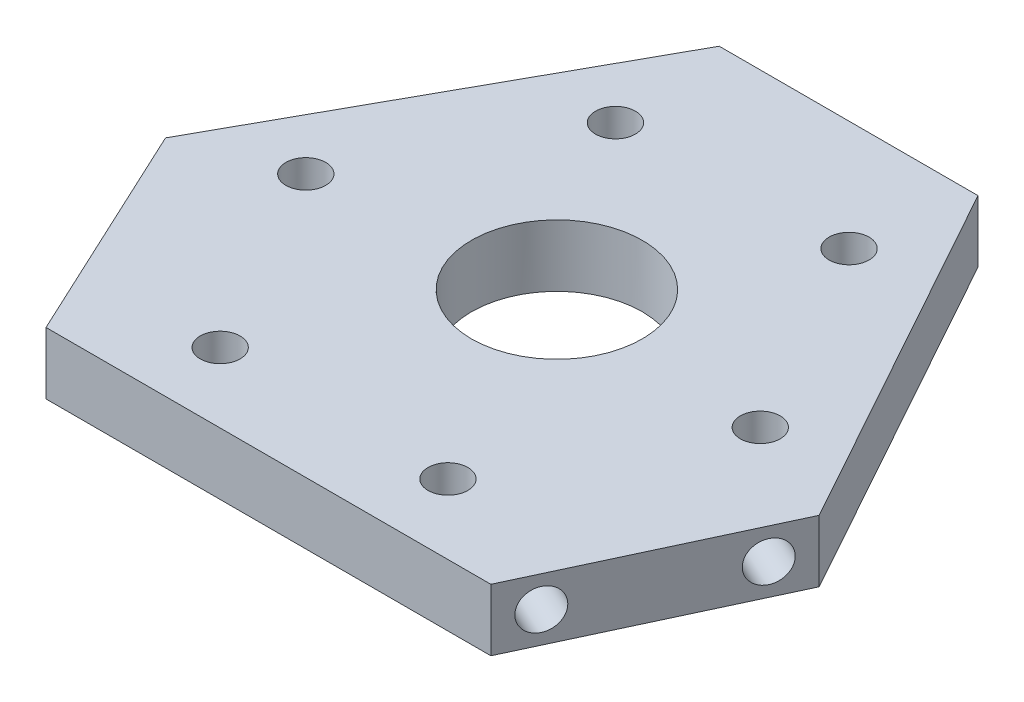
from build123d import *

# Parameters (mm, degrees)
BOSS_EXTRUDE1_DEPTH = 6.5
SCALE1_SCALE        = 0.85
SKETCH2_R           = 9
CUT_EXTRUDE1_DEPTH  = 10
SKETCH7_R           = 2.1
CUT_EXTRUDE7_DEPTH  = 6
SKETCH8_R           = 2.1
CUT_EXTRUDE8_DEPTH  = 6
SKETCH9_R           = 2.1
CUT_EXTRUDE9_DEPTH  = 6
SKETCH10_R          = 2.1
CUT_EXTRUDE10_DEPTH = 10
SKETCH12_R          = 2.1
SKETCH12_R_2        = 9
BOSS_EXTRUDE2_DEPTH = 0.5
SKETCH13_R          = 2.1
SKETCH13_R_2        = 9
BOSS_EXTRUDE3_DEPTH = 0.5


with BuildPart() as part:
    # Sketch1 → Boss-Extrude1 (new body)
    with BuildSketch(Plane(origin=(0, 0, 0), x_dir=(1, 0, 0), z_dir=(0, 1, 0))):
        Polygon((1.965722873, 0), (57.111381005, 0), (70.055583492, 27.758931813), (45.577412376, 71.918721468), (13.499691502, 71.918721468), (-10.978479614, 27.758931813), align=None)
    extrude(amount=BOSS_EXTRUDE1_DEPTH)


with BuildPart() as part_1:
    # Scale1: scaled about (29.538551939, 3.25, -32.913795141)
    add(part.part.scale(SCALE1_SCALE).moved(Location((4.430782791, 0.4875, -4.937069271))))

    # Sketch2 → Cut-Extrude1 (cut)
    with BuildSketch(Plane(origin=(0, 6.0125, 0), x_dir=(1, 0, 0), z_dir=(0, 1, 0))):
        with Locations((29.561028759, 35.307348014)):
            Circle(SKETCH2_R)
    extrude(amount=-CUT_EXTRUDE1_DEPTH, mode=Mode.SUBTRACT)

    # Sketch7 → Cut-Extrude7 (cut)
    with BuildSketch(Plane(origin=(6.902862477, 0, -3.218857636), x_dir=(0.422618262, 0, 0.906307787), z_dir=(-0.906307787, 0, 0.422618262))):
        with Locations((-23.930140333, 3.2525)):
            Circle(SKETCH7_R)
        with Locations((-5.895836778, 3.2525)):
            Circle(SKETCH7_R)
    extrude(amount=-CUT_EXTRUDE7_DEPTH, mode=Mode.SUBTRACT)

    # Sketch8 → Cut-Extrude8 (cut)
    with BuildSketch(Plane(origin=(0, 0, -66.067982519), x_dir=(-1, 0, 0), z_dir=(0, 0, -1))):
        with Locations((-39.17158331, 3.2525)):
            Circle(SKETCH8_R)
        with Locations((-19.905520568, 3.2525)):
            Circle(SKETCH8_R)
    extrude(amount=-CUT_EXTRUDE8_DEPTH, mode=Mode.SUBTRACT)

    # Sketch9 → Cut-Extrude9 (cut)
    with BuildSketch(Plane(origin=(41.622704657, 0, 19.408985935), x_dir=(0.422618262, 0, -0.906307787), z_dir=(0.906307787, 0, 0.422618262))):
        with Locations((30.862899728, 3.2525)):
            Circle(SKETCH9_R)
        with Locations((48.897203282, 3.2525)):
            Circle(SKETCH9_R)
    extrude(amount=-CUT_EXTRUDE9_DEPTH, mode=Mode.SUBTRACT)

    # Sketch10 → Cut-Extrude10 (cut)
    with BuildSketch(Plane.XZ.offset(-0.4875)):
        with Locations((41.211489709, -54.443494734)):
            Circle(SKETCH10_R)
        with Locations((52.846920595, -33.452621763)):
            Circle(SKETCH10_R)
        with Locations((17.41315777, -53.627241783)):
            Circle(SKETCH10_R)
        with Locations((5.777726884, -32.636368812)):
            Circle(SKETCH10_R)
        with Locations((17.101647233, -12.287069271)):
            Circle(SKETCH10_R)
        with Locations((41.101647233, -12.287069271)):
            Circle(SKETCH10_R)
    extrude(amount=-CUT_EXTRUDE10_DEPTH, mode=Mode.SUBTRACT)

    # Sketch12 → Boss-Extrude2 (add)
    with BuildSketch(Plane(origin=(0, 6.0125, 0), x_dir=(1, 0, 0), z_dir=(0, 1, 0))):
        Polygon((-4.900924881, 28.532161313), (6.101647233, 4.937069271), (52.975456645, 4.937069271), (63.978028759, 28.532161313), (43.17158331, 66.067982519), (15.905520568, 66.067982519), align=None)
        with Locations((17.101647233, 12.287069271)):
            Circle(SKETCH12_R, mode=Mode.SUBTRACT)
        with Locations((41.211489709, 54.443494734)):
            Circle(SKETCH12_R, mode=Mode.SUBTRACT)
        with Locations((29.561028759, 35.307348014)):
            Circle(SKETCH12_R_2, mode=Mode.SUBTRACT)
        with Locations((5.777726884, 32.636368812)):
            Circle(SKETCH12_R, mode=Mode.SUBTRACT)
        with Locations((41.101647233, 12.287069271)):
            Circle(SKETCH12_R, mode=Mode.SUBTRACT)
        with Locations((52.846920595, 33.452621763)):
            Circle(SKETCH12_R, mode=Mode.SUBTRACT)
        with Locations((17.41315777, 53.627241783)):
            Circle(SKETCH12_R, mode=Mode.SUBTRACT)
    extrude(amount=BOSS_EXTRUDE2_DEPTH)

    # Sketch13 → Boss-Extrude3 (add)
    with BuildSketch(Plane.XZ.offset(-0.4875)):
        Polygon((6.101647233, -4.937069271), (-4.900924881, -28.532161313), (15.905520568, -66.067982519), (43.17158331, -66.067982519), (63.978028759, -28.532161313), (52.975456645, -4.937069271), align=None)
        with Locations((41.101647233, -12.287069271)):
            Circle(SKETCH13_R, mode=Mode.SUBTRACT)
        with Locations((17.101647233, -12.287069271)):
            Circle(SKETCH13_R, mode=Mode.SUBTRACT)
        with Locations((5.777726884, -32.636368812)):
            Circle(SKETCH13_R, mode=Mode.SUBTRACT)
        with Locations((41.211489709, -54.443494734)):
            Circle(SKETCH13_R, mode=Mode.SUBTRACT)
        with Locations((29.561028759, -35.307348014)):
            Circle(SKETCH13_R_2, mode=Mode.SUBTRACT)
        with Locations((52.846920595, -33.452621763)):
            Circle(SKETCH13_R, mode=Mode.SUBTRACT)
        with Locations((17.41315777, -53.627241783)):
            Circle(SKETCH13_R, mode=Mode.SUBTRACT)
    extrude(amount=BOSS_EXTRUDE3_DEPTH)


solid = part_1.part
